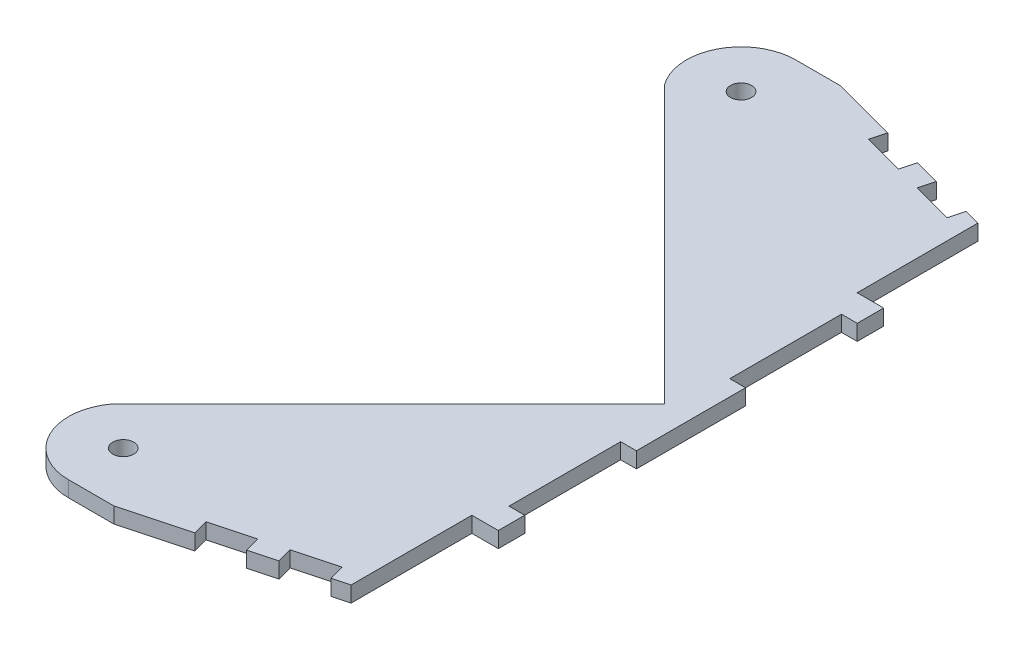
from build123d import *

# Parameters (mm, degrees)
SKETCH1_R           = 3.175
BOSS_EXTRUDE1_DEPTH = 4.7625
SKETCH3_W           = 4.7625
SKETCH3_H           = 33.783
CUT_EXTRUDE2_DEPTH  = 10


with BuildPart() as part:
    # Sketch1 → Boss-Extrude1 (new body)
    with BuildSketch(Plane(origin=(0, 0, 0), x_dir=(1, 0, 0), z_dir=(0, 1, 0))):
        with BuildLine():
            Line((0, 0), (-83.629476528, 83.629476528))
            ThreePointArc((-83.629476528, 83.629476528), (-85.081850373, 100.91197572), (-70.310188895, 110))
            Line((-70.310188895, 110), (-56.601944845, 110))
            Line((-56.601944845, 110), (0, 94.833554589))
            Line((0, 94.833554589), (0, 58.293))
            Line((0, 58.293), (8, 58.293))
            Line((8, 58.293), (8, -58.293))
            Line((8, -58.293), (0, -58.293))
            Line((0, -58.293), (0, -94.833554589))
            Line((0, -94.833554589), (-56.601944845, -110))
            Line((-56.601944845, -110), (-70.310188895, -110))
            ThreePointArc((-70.310188895, -110), (-85.081850373, -100.91197572), (-83.629476528, -83.629476528))
            Line((-83.629476528, -83.629476528), (0, 0))
        make_face()
        with Locations((-70.310188895, 93.451069294)):
            Circle(SKETCH1_R, mode=Mode.SUBTRACT)
        with Locations((-70.310188895, -93.451069294)):
            Circle(SKETCH1_R, mode=Mode.SUBTRACT)
    extrude(amount=BOSS_EXTRUDE1_DEPTH)

    # Sketch3 → Cut-Extrude2 (cut)
    with BuildSketch(Plane(origin=(0, 0, 0), x_dir=(1, 0, 0), z_dir=(0, 1, 0))):
        Polygon((-37.283428319, 104.823619098), (-24.920232031, 101.510910637), (-26.152857733, 96.910688889), (-38.516054022, 100.22339735), align=None)
        Polygon((-17.19282542, 99.440358276), (-4.829629131, 96.127649814), (-6.062254834, 91.527428067), (-18.425451123, 94.840136528), align=None)
        Polygon((-18.425451123, -94.840136528), (-6.062254834, -91.527428067), (-4.829629131, -96.127649814), (-17.19282542, -99.440358276), align=None)
        Polygon((-38.516054022, -100.22339735), (-26.152857733, -96.910688889), (-24.920232031, -101.510910637), (-37.283428319, -104.823619098), align=None)
        with Locations((5.61875, 33.4015)):
            Rectangle(SKETCH3_W, SKETCH3_H)
        with Locations((5.61875, -33.4015)):
            Rectangle(SKETCH3_W, SKETCH3_H)
    extrude(amount=CUT_EXTRUDE2_DEPTH, mode=Mode.SUBTRACT)


solid = part.part
